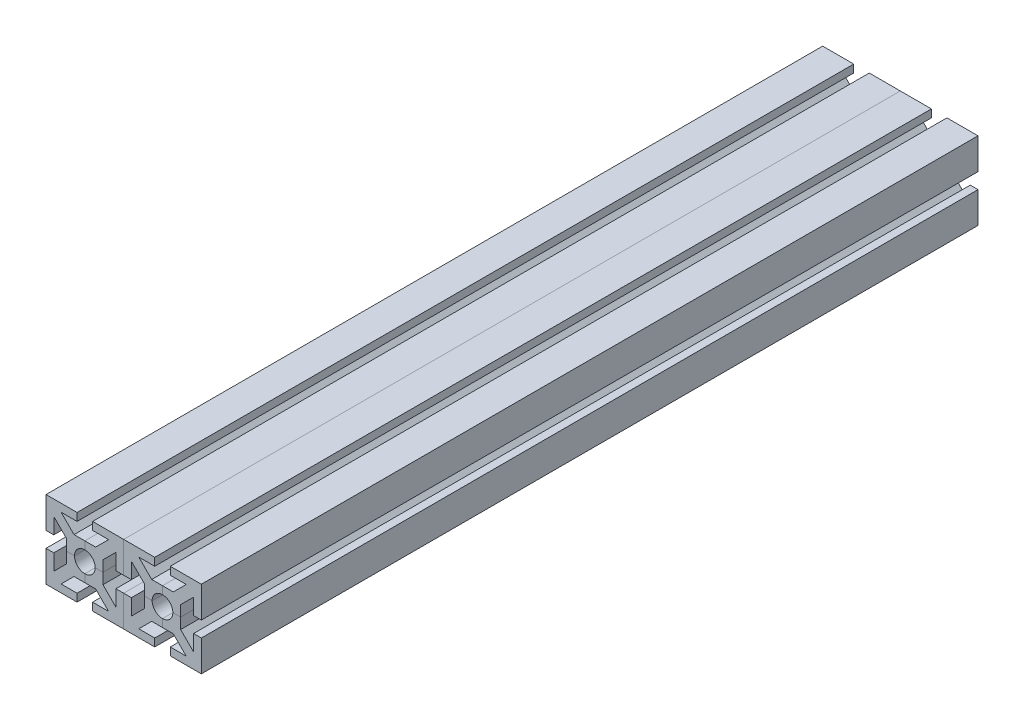
from build123d import *

# Parameters (mm, degrees)
SALIENTE_EXTRUIR1_DEPTH = 150
MATRIZC4_COUNT          = 4


with BuildPart() as part:
    # Croquis1 → Saliente-Extruir1 (new body, symmetric)
    with BuildSketch(Plane.XY):
        with BuildLine():
            Line((0, 4), (0, 7))
            Line((0, 7), (4.171572875, 7))
            Line((4.171572875, 7), (9.171572875, 12))
            Line((9.171572875, 12), (3, 12))
            Line((3, 12), (3, 15))
            Line((3, 15), (15, 15))
            Line((15, 15), (2.828427125, 2.828427125))
            ThreePointArc((2.828427125, 2.828427125), (1.530733729, 3.69551813), (0, 4))
        make_face()
    saliente_extruir1 = extrude(amount=SALIENTE_EXTRUIR1_DEPTH, both=True)

    # Simetría1: Saliente-Extruir1 across plane
    add(saliente_extruir1.mirror(Plane(origin=(2.828427125, 2.828427125, 150), x_dir=(0, 0, 1), z_dir=(-0.707106781, 0.707106781, 0))))


with BuildPart() as matrizc4_1:
    # MatrizC4: pattern copy
    add(part.part.rotate(Axis((0, 0, 0), (0, 0, 1)), 1 * 360 / MATRIZC4_COUNT))


with BuildPart() as matrizc4_2:
    # MatrizC4: pattern copy
    add(part.part.rotate(Axis((0, 0, 0), (0, 0, 1)), 2 * 360 / MATRIZC4_COUNT))


with BuildPart() as matrizc4_3:
    # MatrizC4: pattern copy
    add(part.part.rotate(Axis((0, 0, 0), (0, 0, 1)), 3 * 360 / MATRIZC4_COUNT))


with BuildPart() as body_5:
    # Simetría2: mirrored copy
    add(matrizc4_2.part.mirror(Plane(origin=(15, 3, 150), x_dir=(0, 0, 1), z_dir=(1, 0, 0))))


with BuildPart() as body_6:
    # Simetr_a2 2: mirrored copy
    add(matrizc4_1.part.mirror(Plane(origin=(15, 3, 150), x_dir=(0, 0, 1), z_dir=(1, 0, 0))))


with BuildPart() as body_7:
    # Simetr_a2 3: mirrored copy
    add(matrizc4_3.part.mirror(Plane(origin=(15, 3, 150), x_dir=(0, 0, 1), z_dir=(1, 0, 0))))


with BuildPart() as body_8:
    # Simetr_a2 4: mirrored copy
    add(part.part.mirror(Plane(origin=(15, 3, 150), x_dir=(0, 0, 1), z_dir=(1, 0, 0))))


solid = Compound([part.part, matrizc4_1.part, matrizc4_2.part, matrizc4_3.part, body_5.part, body_6.part, body_7.part, body_8.part])
